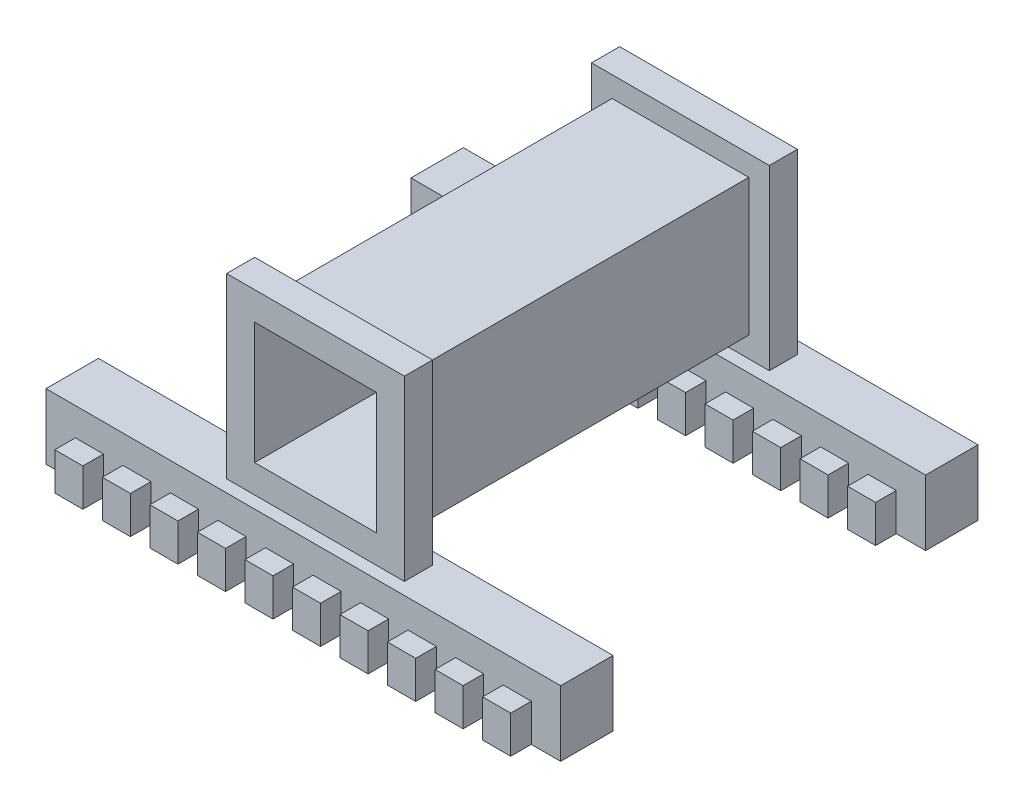
from build123d import *

# Parameters (mm, degrees)
EXTRUDE_1_DEPTH      = 21
SKETCH_1_3_W         = 13
SKETCH_1_3_H         = 13
CUT_EXTRUDE_1_DEPTH  = 21
SKETCH_1_12_W        = 19
SKETCH_1_12_H        = 19
SKETCH_1_12_W_2      = 14.6
SKETCH_1_12_H_2      = 14.6
SKETCH_1_12_W_3      = 13
SKETCH_1_12_H_3      = 13
CUT_EXTRUDE_6_DEPTH  = 18
CUT_EXTRUDE_7_DEPTH  = 14.5
SKETCH_4_W           = 3.504900739
SKETCH_4_H           = 7
SKETCH_4_W_2         = 3.5
EXTRUDE_2_DEPTH      = 27.5
SKETCH_5_W           = 3
SKETCH_5_H           = 4
CUT_EXTRUDE_9_DEPTH  = 2.2
SKETCH_6_W           = 3
SKETCH_6_H           = 4
CUT_EXTRUDE_10_DEPTH = 2.2
SKETCH_7_W           = 3
SKETCH_7_H           = 4
CUT_EXTRUDE_11_DEPTH = 2.2
SKETCH_8_W           = 3
SKETCH_8_H           = 4
CUT_EXTRUDE_12_DEPTH = 2.2
SKETCH_9_W           = 48.11932453
SKETCH_9_H           = 5.1
CUT_EXTRUDE_13_DEPTH = 4


with BuildPart() as part:
    # 草图1 → 凸台-拉伸1 (new, symmetric)
    with BuildSketch(Plane.XY):
        Polygon((9.5, 9.5), (-9.5, 9.5), (-9.5, -9.5), (-27.5, -9.5), (-27.5, -16.5), (27.5, -16.5), (27.5, -9.5), (9.5, -9.5), align=None)
    extrude(amount=EXTRUDE_1_DEPTH, both=True)

    # 草图1<3> → 切除-拉伸1 (cut, symmetric)
    with BuildSketch(Plane.XY):
        Rectangle(SKETCH_1_3_W, SKETCH_1_3_H)
    extrude(amount=CUT_EXTRUDE_1_DEPTH, both=True, mode=Mode.SUBTRACT)

    # 草图1<12> → 切除-拉伸6 (cut, symmetric)
    # profile 1 of 2: a face of its own
    with BuildSketch(Plane.XY):
        Rectangle(SKETCH_1_12_W, SKETCH_1_12_H)
        Rectangle(SKETCH_1_12_W_2, SKETCH_1_12_H_2, mode=Mode.SUBTRACT)
    # profile 2 of 2: a face of its own
    with BuildSketch(Plane.XY):
        Rectangle(SKETCH_1_12_W_3, SKETCH_1_12_H_3)
    extrude(amount=CUT_EXTRUDE_6_DEPTH, both=True, mode=Mode.SUBTRACT)

    # 草图1<13> → 切除-拉伸7 (cut, symmetric)
    with BuildSketch(Plane.XY):
        Polygon((9.5, -9.5), (-9.5, -9.5), (-27.5, -9.5), (-27.5, -16.5), (27.5, -16.5), (27.5, -9.5), align=None)
    extrude(amount=CUT_EXTRUDE_7_DEPTH, both=True, mode=Mode.SUBTRACT)

    # 草图4 → 凸台-拉伸2 (add, symmetric)
    with BuildSketch(Plane(origin=(0, 0, 0), x_dir=(0, 0, -1), z_dir=(1, 0, 0))):
        with Locations((-22.752450369, -13)):
            Rectangle(SKETCH_4_W, SKETCH_4_H)
        with Locations((22.75, -13)):
            Rectangle(SKETCH_4_W_2, SKETCH_4_H)
    extrude(amount=EXTRUDE_2_DEPTH, both=True)

    # 草图5 → 切除-拉伸9 (cut)
    with BuildSketch(Plane(origin=(0, 0, -24.5), x_dir=(-1, 0, 0), z_dir=(0, 0, -1))):
        Polygon((24.35864906, -16.5), (27.5, -16.5), (27.5, -9.5), (9.5, -9.5), (-9.5, -9.5), (-27.5, -9.5), (-27.5, -16.5), (-24.36, -16.5), (-24.36, -12.503647236), (-21.36, -12.503647236), (-21.36, -16.5), (-19.28, -16.5), (-19.28, -12.503647236), (-16.28, -12.503647236), (-16.28, -16.5), (-14.213019691, -16.5), (-14.213019691, -12.503647236), (-11.186980309, -12.503647236), (-11.186980309, -16.5), (-9.12, -16.5), (-9.12, -12.503647236), (-6.12, -12.503647236), (-6.12, -16.5), (1.038031299, -16.5), (1.038031299, -12.495586292), (4.04, -12.495586292), (4.04, -16.5), (6.12, -16.5), (6.12, -12.5), (9.12, -12.5), (9.12, -16.5), (11.198647667, -16.5), (11.198647667, -12.5), (14.201352333, -12.5), (14.201352333, -16.5), (21.36, -16.5), (21.36, -12.487022539), (24.35864906, -12.487022539), align=None)
        with Locations((-2.54, -14.497793146)):
            Rectangle(SKETCH_5_W, SKETCH_5_H, mode=Mode.SUBTRACT)
        with Locations((17.78, -14.493511269)):
            Rectangle(SKETCH_5_W, SKETCH_5_H, mode=Mode.SUBTRACT)
    extrude(amount=-CUT_EXTRUDE_9_DEPTH, mode=Mode.SUBTRACT)

    # 草图6 → 切除-拉伸10 (cut)
    with BuildSketch(Plane.XY.offset(-14.5)):
        Polygon((24.36, -16.5), (27.5, -16.5), (27.5, -9.5), (-27.5, -9.5), (-27.5, -16.5), (-24.35864906, -16.5), (-24.35864906, -12.487022539), (-21.36, -12.487022539), (-21.36, -16.5), (-14.201352333, -16.5), (-14.201352333, -12.5), (-11.198647667, -12.5), (-11.198647667, -16.5), (-9.12, -16.5), (-9.12, -12.5), (-6.12, -12.5), (-6.12, -16.5), (-4.04, -16.5), (-4.04, -12.495586292), (-1.038031299, -12.495586292), (-1.038031299, -16.5), (6.12, -16.5), (6.12, -12.503647236), (9.12, -12.503647236), (9.12, -16.5), (11.186980309, -16.5), (11.186980309, -12.503647236), (14.213019691, -12.503647236), (14.213019691, -16.5), (16.28, -16.5), (16.28, -12.503647236), (19.28, -12.503647236), (19.28, -16.5), (21.36, -16.5), (21.36, -12.503647236), (24.36, -12.503647236), align=None)
        with Locations((-17.78, -14.493511269)):
            Rectangle(SKETCH_6_W, SKETCH_6_H, mode=Mode.SUBTRACT)
        with Locations((2.54, -14.497793146)):
            Rectangle(SKETCH_6_W, SKETCH_6_H, mode=Mode.SUBTRACT)
    extrude(amount=-CUT_EXTRUDE_10_DEPTH, mode=Mode.SUBTRACT)

    # 草图7 → 切除-拉伸11 (cut)
    with BuildSketch(Plane(origin=(0, 0, 14.5), x_dir=(-1, 0, 0), z_dir=(0, 0, -1))):
        Polygon((27.5, -9.5), (-27.5, -9.5), (-27.5, -16.5), (-24.36, -16.5), (-24.36, -12.503647236), (-21.36, -12.503647236), (-21.36, -16.5), (-19.28, -16.5), (-19.28, -12.503647236), (-16.28, -12.503647236), (-16.28, -16.5), (-14.213019691, -16.5), (-14.213019691, -12.503647236), (-11.186980309, -12.503647236), (-11.186980309, -16.5), (-9.12, -16.5), (-9.12, -12.503647236), (-6.12, -12.503647236), (-6.12, -16.5), (1.038031299, -16.5), (1.038031299, -12.495586292), (4.04, -12.495586292), (4.04, -16.5), (6.12, -16.5), (6.12, -12.5), (9.12, -12.5), (9.12, -16.5), (11.198647667, -16.5), (11.198647667, -12.5), (14.201352333, -12.5), (14.201352333, -16.5), (21.36, -16.5), (21.36, -12.487022539), (24.35864906, -12.487022539), (24.35864906, -16.5), (27.5, -16.5), align=None)
        with Locations((-2.54, -14.497793146)):
            Rectangle(SKETCH_7_W, SKETCH_7_H, mode=Mode.SUBTRACT)
        with Locations((17.78, -14.493511269)):
            Rectangle(SKETCH_7_W, SKETCH_7_H, mode=Mode.SUBTRACT)
    extrude(amount=-CUT_EXTRUDE_11_DEPTH, mode=Mode.SUBTRACT)

    # 草图8 → 切除-拉伸12 (cut)
    with BuildSketch(Plane.XY.offset(24.504900739)):
        Polygon((27.5, -9.5), (-27.5, -9.5), (-27.5, -16.5), (-24.35864906, -16.5), (-24.35864906, -12.487022539), (-21.36, -12.487022539), (-21.36, -16.5), (-14.201352333, -16.5), (-14.201352333, -12.5), (-11.198647667, -12.5), (-11.198647667, -16.5), (-9.12, -16.5), (-9.12, -12.5), (-6.12, -12.5), (-6.12, -16.5), (-4.04, -16.5), (-4.04, -12.495586292), (-1.038031299, -12.495586292), (-1.038031299, -16.5), (6.12, -16.5), (6.12, -12.503647236), (9.12, -12.503647236), (9.12, -16.5), (11.186980309, -16.5), (11.186980309, -12.503647236), (14.213019691, -12.503647236), (14.213019691, -16.5), (16.28, -16.5), (16.28, -12.503647236), (19.28, -12.503647236), (19.28, -16.5), (21.36, -16.5), (21.36, -12.503647236), (24.36, -12.503647236), (24.36, -16.5), (27.5, -16.5), align=None)
        with Locations((-17.78, -14.493511269)):
            Rectangle(SKETCH_8_W, SKETCH_8_H, mode=Mode.SUBTRACT)
        with Locations((2.54, -14.497793146)):
            Rectangle(SKETCH_8_W, SKETCH_8_H, mode=Mode.SUBTRACT)
    extrude(amount=-CUT_EXTRUDE_12_DEPTH, mode=Mode.SUBTRACT)

    # 草图9 → 切除-拉伸13 (cut)
    with BuildSketch(Plane.XZ.offset(16.5)):
        with Locations((0.000337735, -19.5)):
            Rectangle(SKETCH_9_W, SKETCH_9_H)
        with Locations((0.000337735, 19.5)):
            Rectangle(SKETCH_9_W, SKETCH_9_H)
    extrude(amount=-CUT_EXTRUDE_13_DEPTH, mode=Mode.SUBTRACT)


solid = part.part
